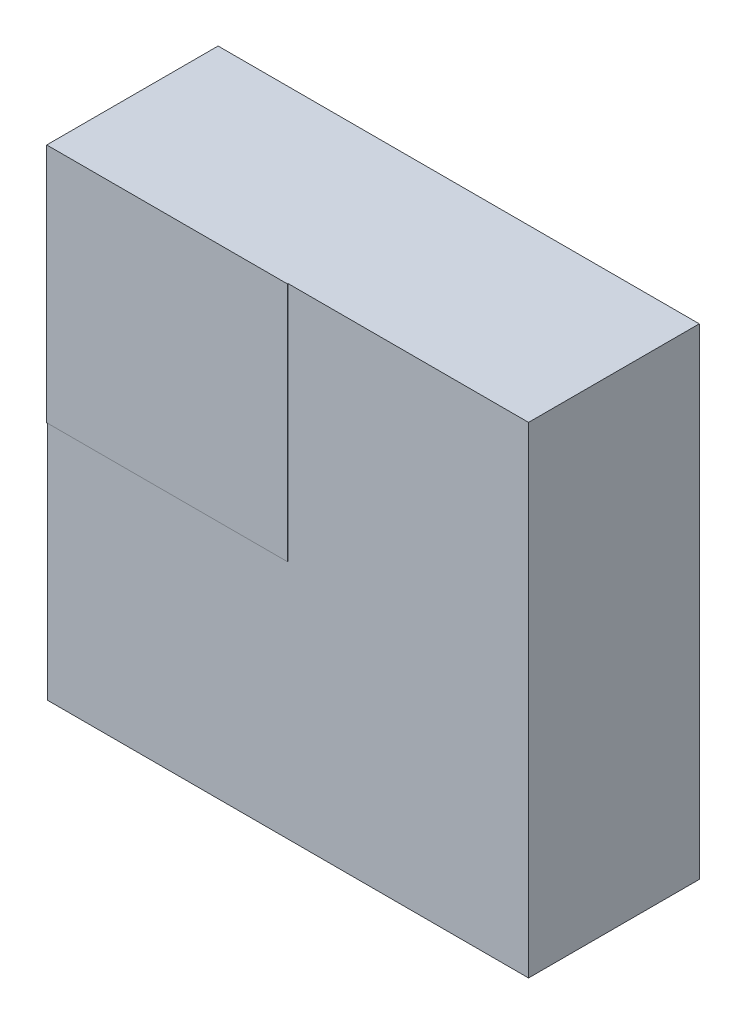
from build123d import *

# Parameters (mm, degrees)
SKETCH1_W            = 0.761
SKETCH1_H            = 0.761
BOSS_EXTRUDE1_DEPTH  = 0.27
SKETCH2_W            = 0.3805
SKETCH2_H            = 0.3805
BOSS_EXTRUDE2_DEPTH  = 0.001
LPATTERN1_COUNT      = 2
LPATTERN1_PITCH      = 0.4
LPATTERN1_COUNT_DIR2 = 2
LPATTERN1_PITCH_DIR2 = 0.4


with BuildPart() as part:
    # Sketch1 → Boss-Extrude1 (new body)
    with BuildSketch(Plane.XY.offset(0.13)):
        Rectangle(SKETCH1_W, SKETCH1_H)
    extrude(amount=BOSS_EXTRUDE1_DEPTH)

    # Sketch2 → Boss-Extrude2 (add)
    with BuildSketch(Plane.XY.offset(0.4)):
        with Locations((-0.19025, 0.19025)):
            Rectangle(SKETCH2_W, SKETCH2_H)
    extrude(amount=BOSS_EXTRUDE2_DEPTH)

    # Sketch3 → Revolve1 (revolve)
    with BuildSketch(Plane(origin=(0, 0.2, 0), x_dir=(1, 0, 0), z_dir=(0, 1, 0))):
        with BuildLine():
            Line((0.2, -0.13), (0.2, 0))
            ThreePointArc((0.2, 0), (0.280622577, -0.040839202), (0.29539392, -0.13))
            Line((0.29539392, -0.13), (0.2, -0.13))
        make_face()
    revolve1 = revolve(axis=Axis((0.2, 0.2, 0.13), (0, 0, -1)))

    # LPattern1: Revolve1 2 × 2
    with Locations(*[(-i * LPATTERN1_PITCH, -j * LPATTERN1_PITCH_DIR2, 0) for i in range(LPATTERN1_COUNT) for j in range(LPATTERN1_COUNT_DIR2) if (i, j) != (0, 0)]):
        add(revolve1)


solid = part.part
